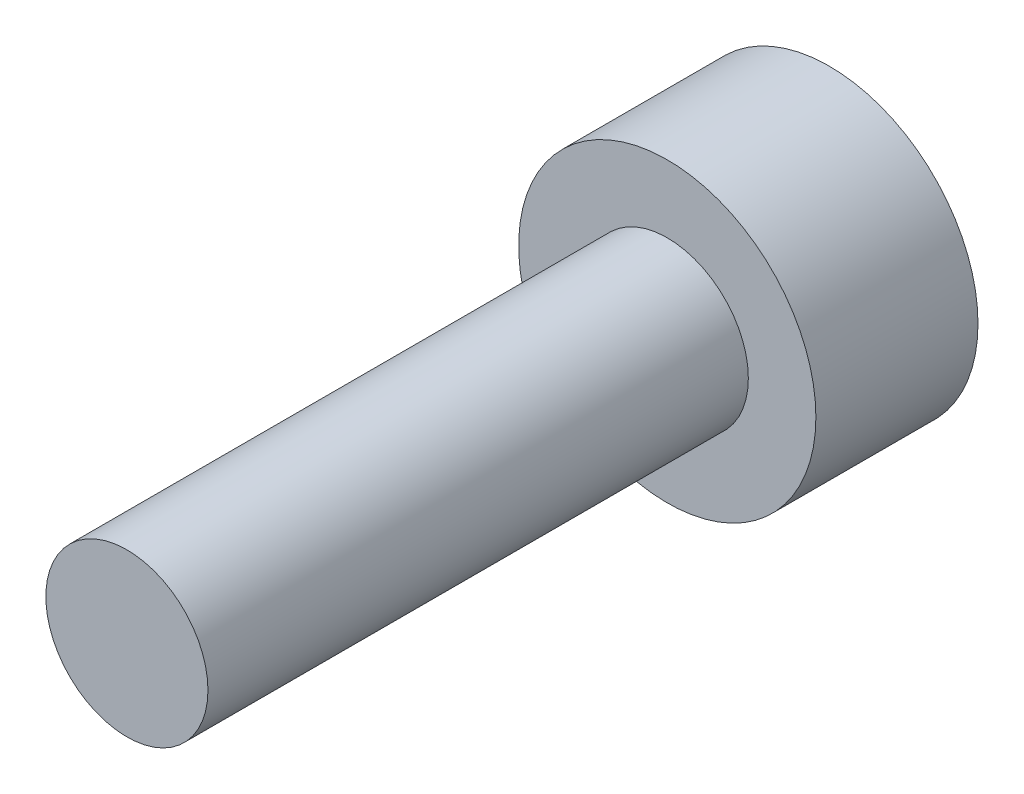
from build123d import *

# Parameters (mm, degrees)
CORTE_EXTRUS_O1_DEPTH = 1.5


with BuildPart() as part:
    # Esboço1 → Revolução1 (revolve)
    with BuildSketch(Plane(origin=(0, 0, 0), x_dir=(1, 0, 0), z_dir=(0, 1, 0))):
        Polygon((0, 0), (2.75, 0), (2.75, -3), (1.5, -3), (1.5, -13), (0, -13), (0, -3), align=None)
    revolve(axis=Axis((0, 0, 3), (0, 0, -1)))

    # Esboço2 → Corte-extrusão1 (cut)
    with BuildSketch(Plane(origin=(0, 0, 0), x_dir=(-1, 0, 0), z_dir=(0, 0, -1))):
        Polygon((1.732050808, 0), (0.866025404, 1.5), (-0.866025404, 1.5), (-1.732050808, 0), (-0.866025404, -1.5), (0.866025404, -1.5), align=None)
    extrude(amount=-CORTE_EXTRUS_O1_DEPTH, mode=Mode.SUBTRACT)


solid = part.part
